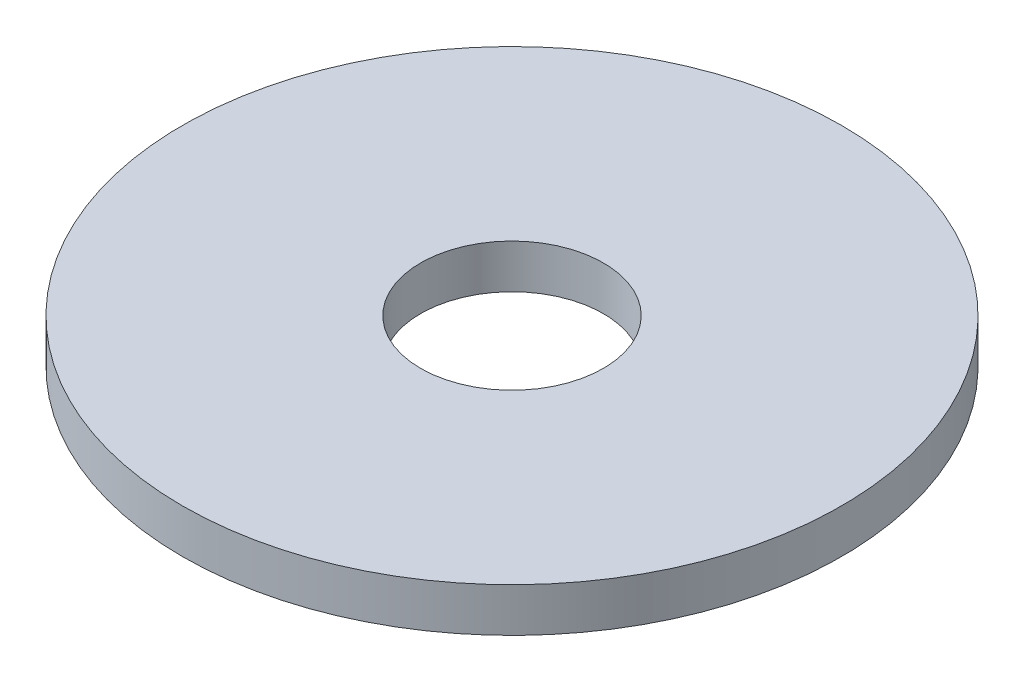
from build123d import *

# Parameters (mm, degrees)
SKETCH1_R           = 9.525
SKETCH1_R_2         = 2.6416
BOSS_EXTRUDE1_DEPTH = 1.27


with BuildPart() as part:
    # Sketch1 → Boss-Extrude1 (new body)
    with BuildSketch(Plane(origin=(0, 0, 0), x_dir=(1, 0, 0), z_dir=(0, 1, 0))):
        Circle(SKETCH1_R)
        Circle(SKETCH1_R_2, mode=Mode.SUBTRACT)
    extrude(amount=BOSS_EXTRUDE1_DEPTH)


solid = part.part
